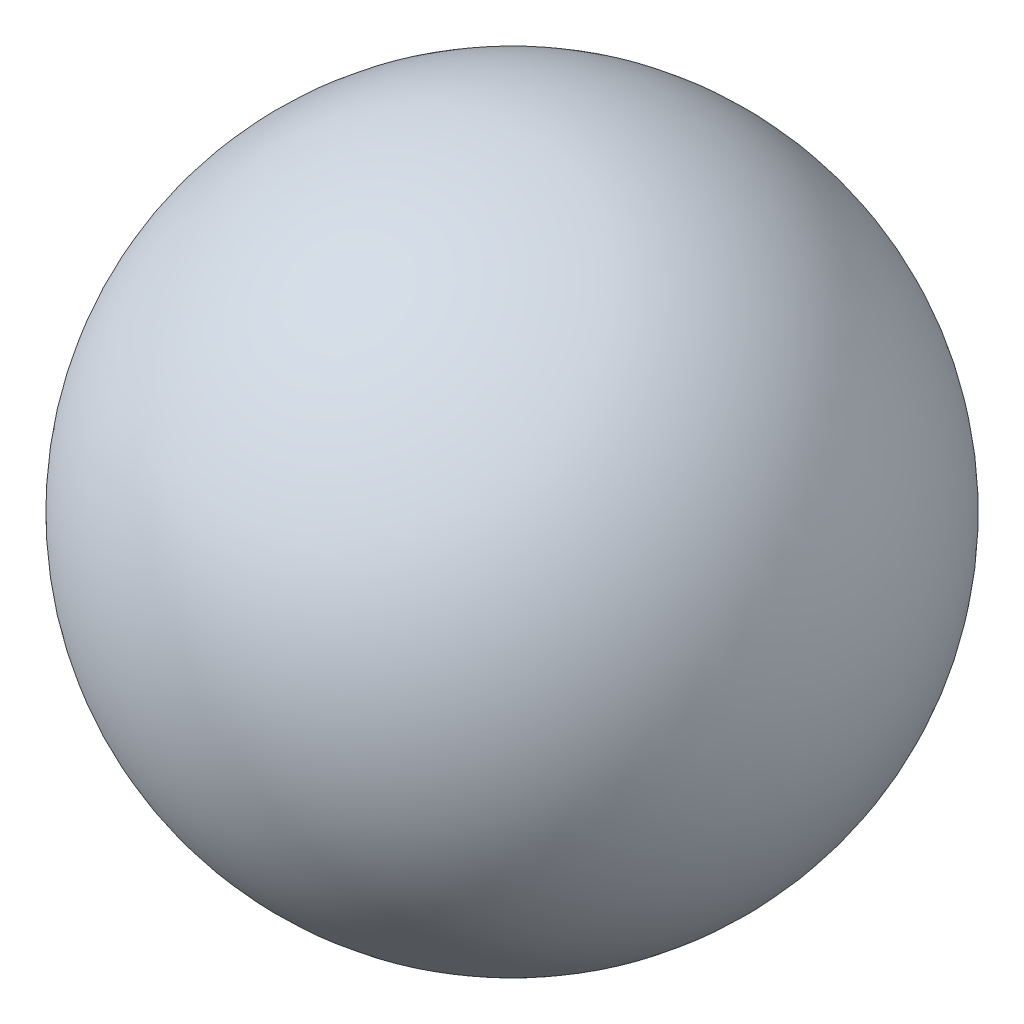
from build123d import *


with BuildPart() as part:
    # Sketch1 → Revolve7 (revolve)
    with BuildSketch(Plane.XY):
        with BuildLine():
            Line((0, 25.4), (0, 22.86))
            ThreePointArc((0, 22.86), (-22.86, 0), (0, -22.86))
            Line((0, -22.86), (0, -25.4))
            ThreePointArc((0, -25.4), (-25.4, 0), (0, 25.4))
        make_face()
    revolve(axis=Axis((0, 25.4, 0), (0, -1, 0)))


solid = part.part
